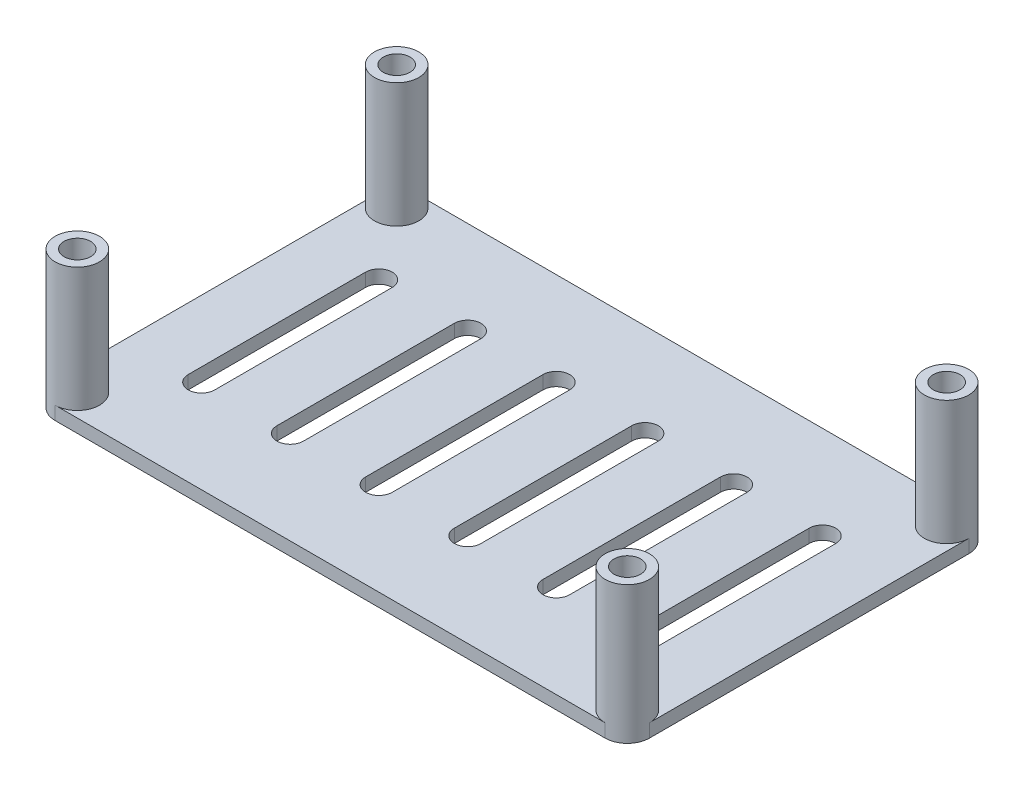
from build123d import *

# Parameters (mm, degrees)
SKETCH3_R             = 2.5
SKETCH3_R_2           = 1.5
BOSS_EXTRUDE2_DEPTH   = 14
BOSS_EXTRUDE2_2_DEPTH = 14
BOSS_EXTRUDE2_3_DEPTH = 14
BOSS_EXTRUDE2_4_DEPTH = 14
BOSS_EXTRUDE3_DEPTH   = 1.5
SKETCH5_R             = 1.5
CUT_EXTRUDE1_DEPTH    = 1.5
CUT_EXTRUDE2_DEPTH    = 1.5


with BuildPart() as part:
    # Sketch3 → Boss-Extrude2 (new body)
    with BuildSketch(Plane(origin=(0, 0, 0), x_dir=(1, 0, 0), z_dir=(0, 1, 0))):
        with Locations((-31, 18)):
            Circle(SKETCH3_R)
        with Locations((-31, 18)):
            Circle(SKETCH3_R_2, mode=Mode.SUBTRACT)
    extrude(amount=BOSS_EXTRUDE2_DEPTH)



with BuildPart() as body_2:
    # Sketch3 → Boss-Extrude2 2 (new body)
    with BuildSketch(Plane(origin=(0, 0, 0), x_dir=(1, 0, 0), z_dir=(0, 1, 0))):
        with Locations((31, 18)):
            Circle(SKETCH3_R)
        with Locations((31, 18)):
            Circle(SKETCH3_R_2, mode=Mode.SUBTRACT)
    extrude(amount=BOSS_EXTRUDE2_2_DEPTH)


with BuildPart() as body_3:
    # Sketch3 → Boss-Extrude2 3 (new body)
    with BuildSketch(Plane(origin=(0, 0, 0), x_dir=(1, 0, 0), z_dir=(0, 1, 0))):
        with Locations((31, -18)):
            Circle(SKETCH3_R)
        with Locations((31, -18)):
            Circle(SKETCH3_R_2, mode=Mode.SUBTRACT)
    extrude(amount=BOSS_EXTRUDE2_3_DEPTH)


with BuildPart() as body_4:
    # Sketch3 → Boss-Extrude2 4 (new body)
    with BuildSketch(Plane(origin=(0, 0, 0), x_dir=(1, 0, 0), z_dir=(0, 1, 0))):
        with Locations((-31, -18)):
            Circle(SKETCH3_R)
        with Locations((-31, -18)):
            Circle(SKETCH3_R_2, mode=Mode.SUBTRACT)
    extrude(amount=BOSS_EXTRUDE2_4_DEPTH)


with BuildPart() as part_1:
    add(part.part)

    add(body_2.part)  # Boss-Extrude3 merges body 2

    add(body_3.part)  # Boss-Extrude3 merges body 3

    add(body_4.part)  # Boss-Extrude3 merges body 4
    # Sketch4 → Boss-Extrude3 (add)
    with BuildSketch(Plane.XZ):
        with BuildLine():
            Line((-31, 20.5), (31, 20.5))
            ThreePointArc((31, 20.5), (32.767766953, 19.767766953), (33.5, 18))
            Line((33.5, 18), (33.5, -18))
            ThreePointArc((33.5, -18), (32.767766953, -19.767766953), (31, -20.5))
            Line((31, -20.5), (-31, -20.5))
            ThreePointArc((-31, -20.5), (-32.767766953, -19.767766953), (-33.5, -18))
            Line((-33.5, -18), (-33.5, 18))
            ThreePointArc((-33.5, 18), (-32.767766953, 19.767766953), (-31, 20.5))
        make_face()
    extrude(amount=BOSS_EXTRUDE3_DEPTH)

    # Sketch5 → Cut-Extrude1 (cut)
    with BuildSketch(Plane(origin=(0, 0, 0), x_dir=(1, 0, 0), z_dir=(0, 1, 0))):
        with Locations((31, 18)):
            Circle(SKETCH5_R)
        with Locations((-31, 18)):
            Circle(SKETCH5_R)
        with Locations((-31, -18)):
            Circle(SKETCH5_R)
        with Locations((31, -18)):
            Circle(SKETCH5_R)
    extrude(amount=-CUT_EXTRUDE1_DEPTH, mode=Mode.SUBTRACT)

    # Sketch6 → Cut-Extrude2 (cut)
    with BuildSketch(Plane(origin=(0, 0, 0), x_dir=(1, 0, 0), z_dir=(0, 1, 0))):
        with BuildLine():
            Line((-23.5, 10), (-23.5, -10))
            ThreePointArc((-23.5, -10), (-25, -11.5), (-26.5, -10))
            Line((-26.5, -10), (-26.5, 10))
            ThreePointArc((-26.5, 10), (-25, 11.5), (-23.5, 10))
        make_face()
        with BuildLine():
            Line((-13.5, 10), (-13.5, -10))
            ThreePointArc((-13.5, -10), (-15, -11.5), (-16.5, -10))
            Line((-16.5, -10), (-16.5, 10))
            ThreePointArc((-16.5, 10), (-15, 11.5), (-13.5, 10))
        make_face()
        with BuildLine():
            Line((-3.5, 10), (-3.5, -10))
            ThreePointArc((-3.5, -10), (-5, -11.5), (-6.5, -10))
            Line((-6.5, -10), (-6.5, 10))
            ThreePointArc((-6.5, 10), (-5, 11.5), (-3.5, 10))
        make_face()
        with BuildLine():
            Line((6.5, 10), (6.5, -10))
            ThreePointArc((6.5, -10), (5, -11.5), (3.5, -10))
            Line((3.5, -10), (3.5, 10))
            ThreePointArc((3.5, 10), (5, 11.5), (6.5, 10))
        make_face()
        with BuildLine():
            Line((16.5, 10), (16.5, -10))
            ThreePointArc((16.5, -10), (15, -11.5), (13.5, -10))
            Line((13.5, -10), (13.5, 10))
            ThreePointArc((13.5, 10), (15, 11.5), (16.5, 10))
        make_face()
        with BuildLine():
            Line((26.5, 10), (26.5, -10))
            ThreePointArc((26.5, -10), (25, -11.5), (23.5, -10))
            Line((23.5, -10), (23.5, 10))
            ThreePointArc((23.5, 10), (25, 11.5), (26.5, 10))
        make_face()
    extrude(amount=-CUT_EXTRUDE2_DEPTH, mode=Mode.SUBTRACT)


solid = part_1.part
